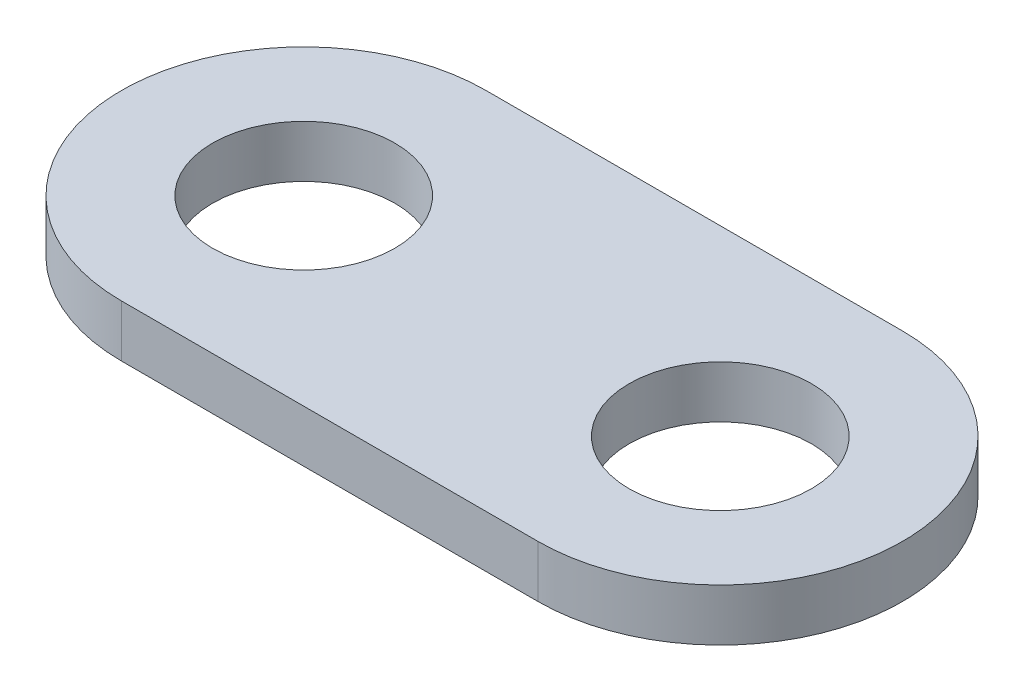
from build123d import *

# Parameters (mm, degrees)
SKETCH1_R           = 17.5
BOSS_EXTRUDE1_DEPTH = 10


with BuildPart() as part:
    # Sketch1 → Boss-Extrude1 (new body)
    with BuildSketch(Plane(origin=(0, 0, 0), x_dir=(1, 0, 0), z_dir=(0, 1, 0))):
        with BuildLine():
            Line((-93.192771084, 30.744483458), (-13.192771084, 30.744483458))
            ThreePointArc((-13.192771084, 30.744483458), (21.807228916, -4.255516542), (-13.192771084, -39.255516542))
            Line((-13.192771084, -39.255516542), (-93.192771084, -39.255516542))
            ThreePointArc((-93.192771084, -39.255516542), (-128.192771084, -4.255516542), (-93.192771084, 30.744483458))
        make_face()
        with Locations((-93.192771084, -4.255516542)):
            Circle(SKETCH1_R, mode=Mode.SUBTRACT)
        with Locations((-13.192771084, -4.255516542)):
            Circle(SKETCH1_R, mode=Mode.SUBTRACT)
    extrude(amount=BOSS_EXTRUDE1_DEPTH)


solid = part.part
